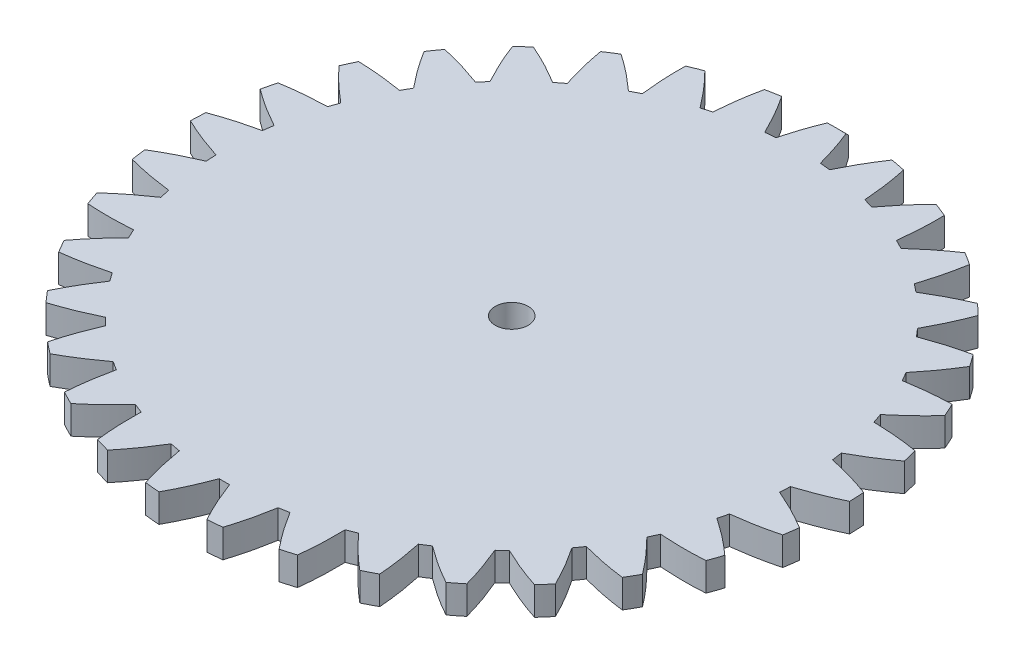
from build123d import *

# Parameters (mm, degrees)
SKETCH_1_R               = 30.5
EXTRUDE_2_DEPTH          = 1.5
EXTRUDE_3_DEPTH          = 3
CHAMFER_2_SIZE           = 0.5
PATTERN_CIRCULAR_1_COUNT = 33
SKETCH_5_R               = 1.75
CUT_EXTRUDE_1_DEPTH      = 4.0000001


with BuildPart() as part:
    # 스케치1 → 보스-돌출2 (new body, symmetric)
    with BuildSketch(Plane(origin=(0, 0, 0), x_dir=(1, 0, 0), z_dir=(0, 1, 0))):
        Circle(SKETCH_1_R)
    extrude(amount=EXTRUDE_2_DEPTH, both=True)

    # 스케치4 → 보스-돌출3 (add)
    with BuildSketch(Plane(origin=(0, 1.5, 0), x_dir=(1, 0, 0), z_dir=(0, 1, 0))):
        with BuildLine():
            add(Edge.make_bspline(
                [(2.355, 30.408945641), (1.732522958, 32.756416745), (0.785, 34.991195678)],
                knots=[0, 0, 0, 1, 1, 1], degree=2))
            ThreePointArc((0.785, 34.991195678), (0, 35), (-0.785, 34.991195678))
            add(Edge.make_bspline(
                [(-2.355, 30.408945641), (-1.732522958, 32.756416745), (-0.785, 34.991195678)],
                knots=[0, 0, 0, 1, 1, 1], degree=2))
            ThreePointArc((-2.355, 30.408945641), (0, 30.5), (2.355, 30.408945641))
        make_face()
    extrude_3 = extrude(amount=-EXTRUDE_3_DEPTH)

    # 모따기2
    chamfer_2_edges = [part.edges().sort_by_distance(p)[0] for p in [
        (0, -1.5, -35),
        (0, 1.5, -35),
    ]]
    chamfer(chamfer_2_edges, length=CHAMFER_2_SIZE)

    # 원형 패턴1: 보스-돌출3 ×33 about axis
    pattern_circular_1_axis = Axis((0, 1.5, 0), (0, -1, 0))
    for i in range(1, PATTERN_CIRCULAR_1_COUNT):
        add(extrude_3.rotate(pattern_circular_1_axis, i * 360 / PATTERN_CIRCULAR_1_COUNT))

    # 스케치5 → 컷-돌출1 (cut, through all)
    with BuildSketch(Plane(origin=(0, 1.5, 0), x_dir=(1, 0, 0), z_dir=(0, 1, 0))):
        Circle(SKETCH_5_R)
    extrude(amount=-CUT_EXTRUDE_1_DEPTH, mode=Mode.SUBTRACT)


solid = part.part
